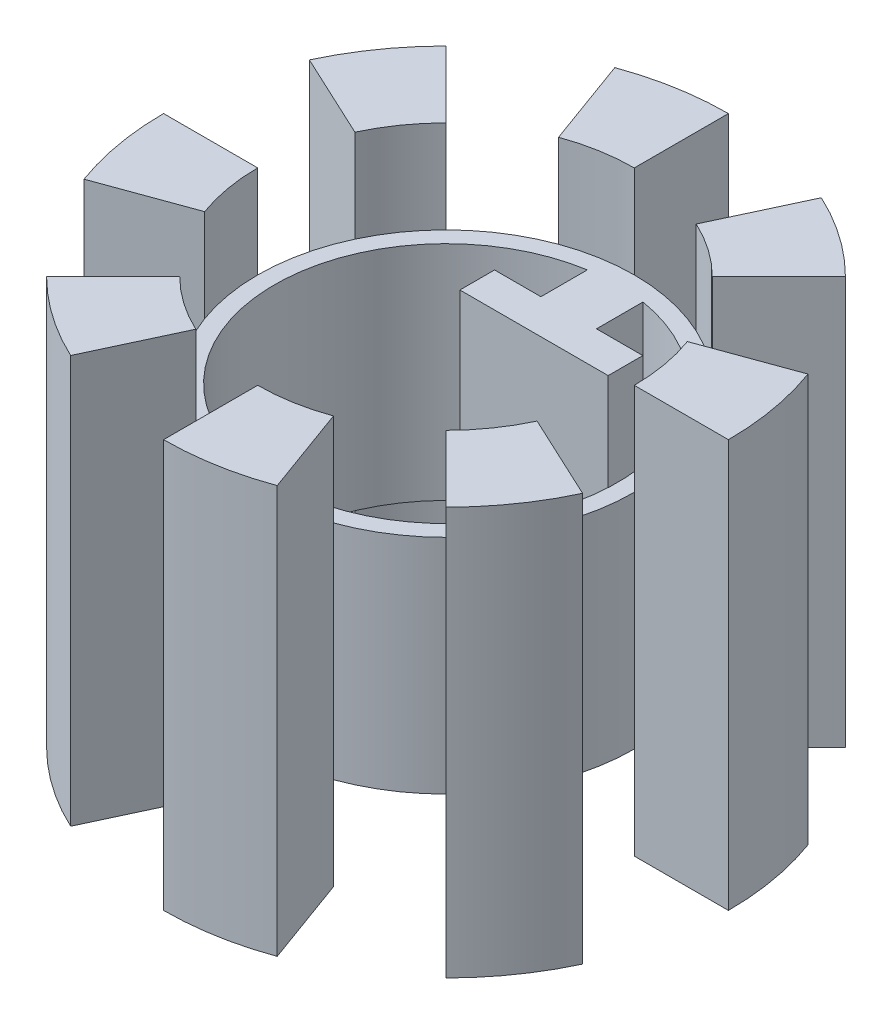
from build123d import *

# Parameters (mm, degrees)
SKETCH1_R           = 10.16
SKETCH1_R_2         = 9.25
BOSS_EXTRUDE1_DEPTH = 12
BOSS_EXTRUDE3_DEPTH = 11
BOSS_EXTRUDE4_DEPTH = 12


with BuildPart() as part:
    # Sketch1 → Boss-Extrude1 (new body)
    with BuildSketch(Plane(origin=(0, 0, 0), x_dir=(1, 0, 0), z_dir=(0, 1, 0))):
        Circle(SKETCH1_R)
        Circle(SKETCH1_R_2, mode=Mode.SUBTRACT)
    extrude(amount=BOSS_EXTRUDE1_DEPTH)

    # Sketch3 → Boss-Extrude3 (add, symmetric)
    with BuildSketch(Plane(origin=(0, 6, 0), x_dir=(-1, 0, 0), z_dir=(0, -1, 0))):
        with BuildLine():
            Line((5.212386984, 14.320915541), (3.474924656, 9.547277027))
            ThreePointArc((3.474924656, 9.547277027), (1.764265485, 10.005646771), (0, 10.16))
            Line((0, 10.16), (0, 15.24))
            ThreePointArc((0, 15.24), (2.646398228, 15.008470156), (5.212386984, 14.320915541))
        make_face()
        with BuildLine():
            Line((10.776307345, 10.776307345), (7.184204897, 7.184204897))
            ThreePointArc((7.184204897, 7.184204897), (8.32258477, 5.827536593), (9.208087116, 4.293801539))
            Line((9.208087116, 4.293801539), (13.812130674, 6.440702309))
            ThreePointArc((13.812130674, 6.440702309), (12.483877155, 8.74130489), (10.776307345, 10.776307345))
        make_face()
        with BuildLine():
            Line((15.24, 0), (10.16, 0))
            ThreePointArc((10.16, 0), (10.005646771, -1.764265485), (9.547277027, -3.474924656))
            Line((9.547277027, -3.474924656), (14.320915541, -5.212386984))
            ThreePointArc((14.320915541, -5.212386984), (15.008470156, -2.646398228), (15.24, 0))
        make_face()
        with BuildLine():
            Line((10.776307345, -10.776307345), (7.184204897, -7.184204897))
            ThreePointArc((7.184204897, -7.184204897), (5.827536593, -8.32258477), (4.293801539, -9.208087116))
            Line((4.293801539, -9.208087116), (6.440702309, -13.812130674))
            ThreePointArc((6.440702309, -13.812130674), (8.74130489, -12.483877155), (10.776307345, -10.776307345))
        make_face()
        with BuildLine():
            Line((0, -15.24), (0, -10.16))
            ThreePointArc((0, -10.16), (-1.764265485, -10.005646771), (-3.474924656, -9.547277027))
            Line((-3.474924656, -9.547277027), (-5.212386984, -14.320915541))
            ThreePointArc((-5.212386984, -14.320915541), (-2.646398228, -15.008470156), (0, -15.24))
        make_face()
        with BuildLine():
            Line((-10.776307345, -10.776307345), (-7.184204897, -7.184204897))
            ThreePointArc((-7.184204897, -7.184204897), (-8.32258477, -5.827536593), (-9.208087116, -4.293801539))
            Line((-9.208087116, -4.293801539), (-13.812130674, -6.440702309))
            ThreePointArc((-13.812130674, -6.440702309), (-12.483877155, -8.74130489), (-10.776307345, -10.776307345))
        make_face()
        with BuildLine():
            Line((-15.24, 0), (-10.16, 0))
            ThreePointArc((-10.16, 0), (-10.005646771, 1.764265485), (-9.547277027, 3.474924656))
            Line((-9.547277027, 3.474924656), (-14.320915541, 5.212386984))
            ThreePointArc((-14.320915541, 5.212386984), (-15.008470156, 2.646398228), (-15.24, 0))
        make_face()
        with BuildLine():
            Line((-10.776307345, 10.776307345), (-7.184204897, 7.184204897))
            ThreePointArc((-7.184204897, 7.184204897), (-5.827536593, 8.32258477), (-4.293801539, 9.208087116))
            Line((-4.293801539, 9.208087116), (-6.440702309, 13.812130674))
            ThreePointArc((-6.440702309, 13.812130674), (-8.74130489, 12.483877155), (-10.776307345, 10.776307345))
        make_face()
    extrude(amount=BOSS_EXTRUDE3_DEPTH, both=True)

    # Sketch4 → Boss-Extrude4 (add)
    with BuildSketch(Plane.XZ):
        with BuildLine():
            Line((-4, -4.75), (-4, -6.620469825))
            Line((-4, -6.620469825), (-1.5, -6.620469825))
            Line((-1.5, -6.620469825), (-1.5, -8.620469825))
            Line((-1.5, -8.620469825), (-1.5, -9.127568132))
            ThreePointArc((-1.5, -9.127568132), (0, -9.25), (1.5, -9.127568132))
            Line((1.5, -9.127568132), (1.5, -8.620469825))
            Line((1.5, -8.620469825), (1.5, -6.620469825))
            Line((1.5, -6.620469825), (4, -6.620469825))
            Line((4, -6.620469825), (4, -4.75))
            Line((4, -4.75), (-4, -4.75))
        make_face()
    extrude(amount=-BOSS_EXTRUDE4_DEPTH)


solid = part.part
